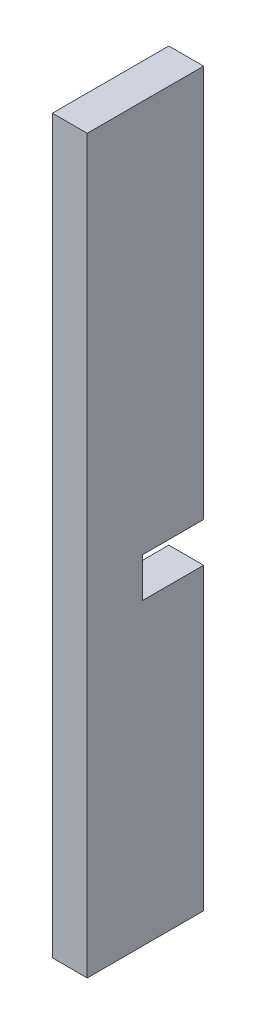
from build123d import *

# Parameters (mm, degrees)
ESQUISSE1_W             = 22
ESQUISSE1_H             = 462
BOSS_EXTRU_1_DEPTH      = 73.5
ESQUISSE2_W             = 38.5
ESQUISSE2_H             = 25
ENL_V_MAT_EXTRU_1_DEPTH = 35


with BuildPart() as part:
    # Esquisse1 → Boss.-Extru.1 (new body)
    with BuildSketch(Plane.XY):
        Rectangle(ESQUISSE1_W, ESQUISSE1_H)
    extrude(amount=BOSS_EXTRU_1_DEPTH)

    # Esquisse2 → Enlèv. mat.-Extru.1 (cut)
    with BuildSketch(Plane.ZY.offset(11)):
        with Locations((19.25, -29.5)):
            Rectangle(ESQUISSE2_W, ESQUISSE2_H)
    extrude(amount=-ENL_V_MAT_EXTRU_1_DEPTH, mode=Mode.SUBTRACT)


solid = part.part
